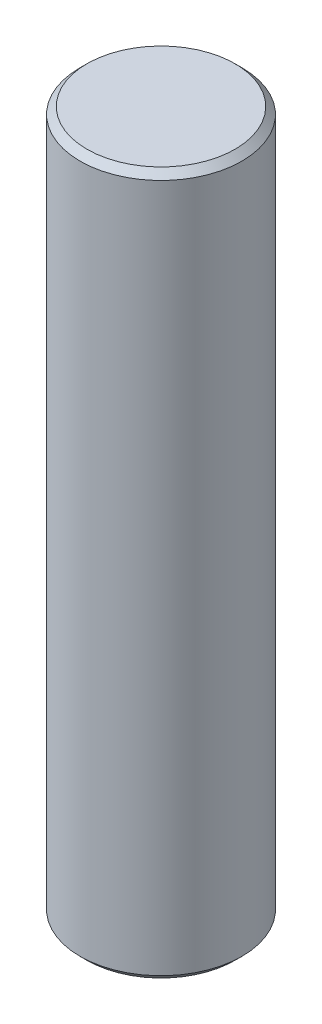
from build123d import *

# Parameters (mm, degrees)
SKETCH1_R           = 2.95
BOSS_EXTRUDE1_DEPTH = 25.6
CHAMFER3_SIZE       = 0.25
CHAMFER4_SIZE       = 0.25


with BuildPart() as part:
    # Sketch1 → Boss-Extrude1 (new body)
    with BuildSketch(Plane(origin=(0, 0, 0), x_dir=(1, 0, 0), z_dir=(0, 1, 0))):
        Circle(SKETCH1_R)
    extrude(amount=-BOSS_EXTRUDE1_DEPTH)

    # Chamfer3
    chamfer3_edges = [part.edges().sort_by_distance(p)[0] for p in [
        (-2.95, -25.6, 0),
    ]]
    chamfer(chamfer3_edges, length=CHAMFER3_SIZE)

    # Chamfer4
    chamfer4_edges = [part.edges().sort_by_distance(p)[0] for p in [
        (-2.95, 0, 0),
    ]]
    chamfer(chamfer4_edges, length=CHAMFER4_SIZE)


solid = part.part
